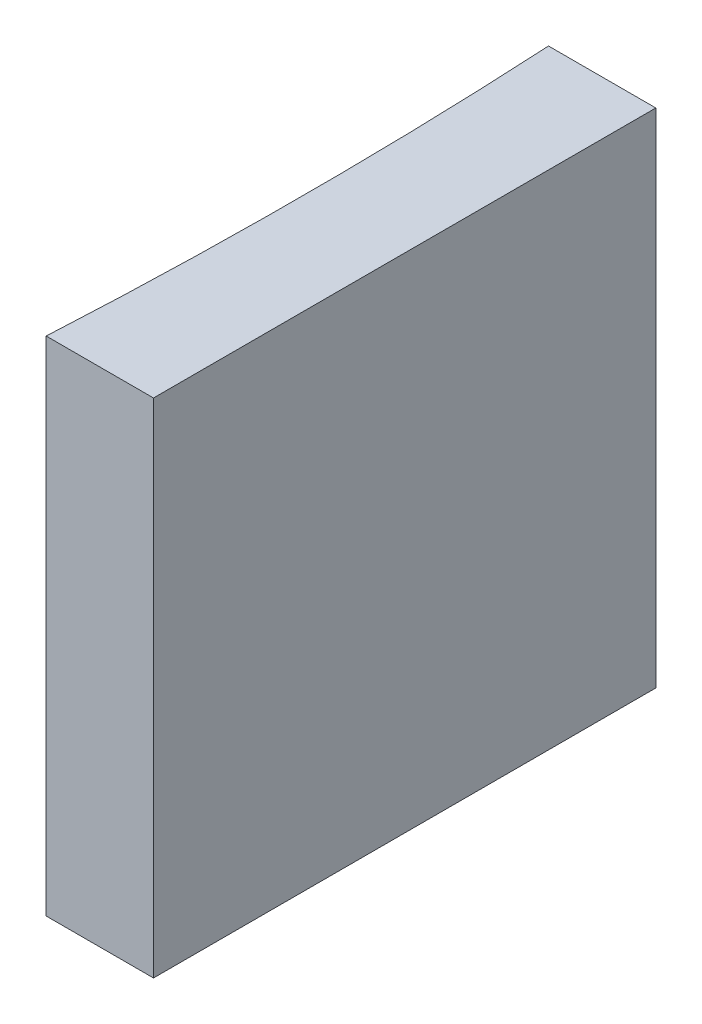
from build123d import *

# Parameters (mm, degrees)
EXTRUDE_1_DEPTH = 10


with BuildPart() as part:
    # 草图1 → 凸台-拉伸1 (new body)
    with BuildSketch(Plane(origin=(0, 0, 0), x_dir=(1, 0, 0), z_dir=(0, 1, 0))):
        with BuildLine():
            Line((0, 0), (0, -10))
            Line((0, -10), (-2.136415535, -10))
            ThreePointArc((-2.136415535, -10), (-2, -5), (-2.136415535, 0))
            Line((-2.136415535, 0), (0, 0))
        make_face()
    extrude(amount=EXTRUDE_1_DEPTH)


solid = part.part
